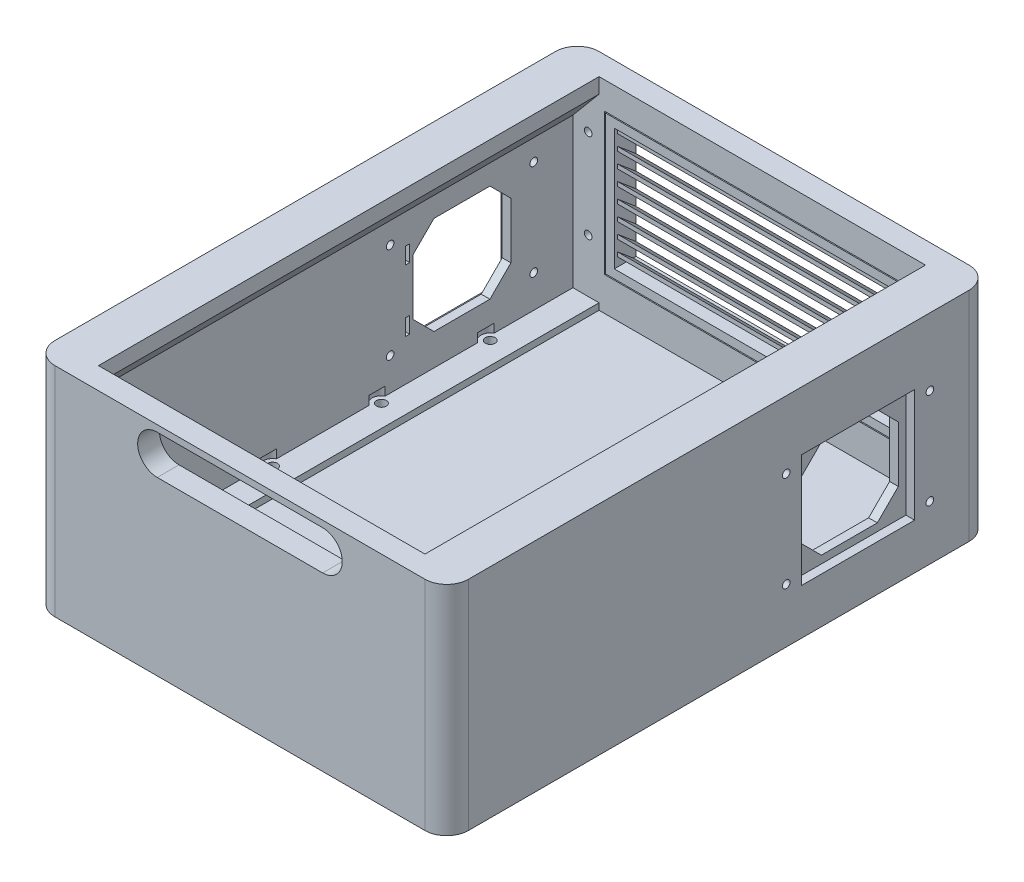
from build123d import *

# Parameters (mm, degrees)
CROQUIS1_W              = 190
CROQUIS1_H              = 250
SALIENTE_EXTRUIR1_DEPTH = 100
VACIADO1_T              = -10
CORTAR_EXTRUIR1_REACH   = 252
REDONDEO1_R             = 10
CROQUIS5_W              = 230
CROQUIS5_H              = 90
SALIENTE_EXTRUIR3_DEPTH = 10
CROQUIS6_W              = 230
CROQUIS6_H              = 90
SALIENTE_EXTRUIR4_DEPTH = 10
CROQUIS7_R              = 2.25
CORTAR_EXTRUIR3_DEPTH   = 10
CROQUIS10_W             = 20
CROQUIS10_H             = 15
CORTAR_EXTRUIR6_DEPTH   = 11
CROQUIS11_W             = 40
CROQUIS11_H             = 60
CORTAR_EXTRUIR7_DEPTH   = 7
CROQUIS13_W             = 145
CROQUIS13_H             = 65
CORTAR_EXTRUIR8_DEPTH   = 10
CROQUIS14_W             = 151
CROQUIS14_H             = 71
CORTAR_EXTRUIR9_DEPTH   = 5
CROQUIS15_W             = 150
CROQUIS15_H             = 70
SALIENTE_EXTRUIR5_DEPTH = 5
CROQUIS16_W             = 144
CROQUIS16_H             = 64
SALIENTE_EXTRUIR6_DEPTH = 5
CROQUIS17_W             = 136
CROQUIS17_H             = 56
CORTAR_EXTRUIR10_DEPTH  = 10
SALIENTE_EXTRUIR7_DEPTH = 136
CROQUIS19_W             = 9
CROQUIS19_H             = 9
CORTAR_EXTRUIR11_DEPTH  = 3.25
CROQUIS20_W             = 9
CROQUIS20_H             = 8
SALIENTE_EXTRUIR8_DEPTH = 3
CROQUIS21_R             = 1.75
CORTAR_EXTRUIR12_DEPTH  = 15
CROQUIS22_R             = 2
CORTAR_EXTRUIR13_DEPTH  = 0.5
CORTAR_EXTRUIR14_DEPTH  = 230
CROQUIS26_R             = 4.25
CORTAR_EXTRUIR15_DEPTH  = 4
CROQUIS25_W             = 52
CROQUIS25_H             = 52
CORTAR_EXTRUIR16_DEPTH  = 4
CORTAR_EXTRUIR17_DEPTH  = 4
CROQUIS29_R             = 1.75
CORTAR_EXTRUIR18_DEPTH  = 8
CROQUIS30_W             = 2
CROQUIS30_H             = 7.5
CORTAR_EXTRUIR19_DEPTH  = 10


with BuildPart() as part:
    # Croquis1 → Saliente-Extruir1 (new body)
    with BuildSketch(Plane(origin=(0, 0, 0), x_dir=(1, 0, 0), z_dir=(0, 1, 0))):
        with Locations((95, 125)):
            Rectangle(CROQUIS1_W, CROQUIS1_H)
    extrude(amount=SALIENTE_EXTRUIR1_DEPTH)

    # Vaciado1
    vaciado1_openings = [part.faces().sort_by_distance(p)[0] for p in [
        (95, 100, -125),
    ]]
    offset(amount=VACIADO1_T, openings=vaciado1_openings, kind=Kind.INTERSECTION)

    # Croquis2 → Cortar-Extruir1 (cut, up to next)
    with BuildSketch(Plane.XY, mode=Mode.PRIVATE) as cortar_extruir1_sk1:
        with BuildLine():
            Line((57, 97), (133, 97))
            ThreePointArc((133, 97), (142, 88), (133, 79))
            Line((133, 79), (57, 79))
            ThreePointArc((57, 79), (48, 88), (57, 97))
        make_face()
    cortar_extruir1_tool1 = extrude(cortar_extruir1_sk1.sketch, amount=-CORTAR_EXTRUIR1_REACH, mode=Mode.PRIVATE) & part.part
    add(cortar_extruir1_tool1.solids().sort_by_distance((95, 88, 0))[0], mode=Mode.SUBTRACT)

    # Redondeo1
    redondeo1_edges = [part.edges().sort_by_distance(p)[0] for p in [
        (0, 50, -250),
        (190, 50, -250),
        (190, 50, 0),
        (0, 50, 0),
    ]]
    fillet(redondeo1_edges, radius=REDONDEO1_R)

    # Croquis5 → Saliente-Extruir3 (add)
    with BuildSketch(Plane(origin=(10, 0, 0), x_dir=(0, 0, -1), z_dir=(1, 0, 0))):
        with Locations((125, 55)):
            Rectangle(CROQUIS5_W, CROQUIS5_H)
    extrude(amount=SALIENTE_EXTRUIR3_DEPTH)

    # Croquis6 → Saliente-Extruir4 (add)
    with BuildSketch(Plane.ZY.offset(-180)):
        with Locations((-125, 55)):
            Rectangle(CROQUIS6_W, CROQUIS6_H)
    extrude(amount=SALIENTE_EXTRUIR4_DEPTH)

    # Croquis7 → Cortar-Extruir3 (cut)
    with BuildSketch(Plane.XZ):
        with Locations((10, -50)):
            Circle(CROQUIS7_R)
        with Locations((10, -100)):
            Circle(CROQUIS7_R)
        with Locations((10, -150)):
            Circle(CROQUIS7_R)
        with Locations((10, -200)):
            Circle(CROQUIS7_R)
        with Locations((180, -200)):
            Circle(CROQUIS7_R)
        with Locations((180, -150)):
            Circle(CROQUIS7_R)
        with Locations((180, -100)):
            Circle(CROQUIS7_R)
        with Locations((180, -50)):
            Circle(CROQUIS7_R)
    extrude(amount=-CORTAR_EXTRUIR3_DEPTH, mode=Mode.SUBTRACT)

    # Croquis10 → Cortar-Extruir6 (cut, through all)
    with BuildSketch(Plane(origin=(0, 10, 0), x_dir=(1, 0, 0), z_dir=(0, 1, 0))):
        with Locations((95, 212)):
            Rectangle(CROQUIS10_W, CROQUIS10_H)
    extrude(amount=-CORTAR_EXTRUIR6_DEPTH, mode=Mode.SUBTRACT)

    # Croquis11 → Cortar-Extruir7 (cut)
    with BuildSketch(Plane(origin=(0, 10, 0), x_dir=(1, 0, 0), z_dir=(0, 1, 0))):
        with Locations((95, 40)):
            Rectangle(CROQUIS11_W, CROQUIS11_H)
    extrude(amount=-CORTAR_EXTRUIR7_DEPTH, mode=Mode.SUBTRACT)

    # Croquis13 → Cortar-Extruir8 (cut)
    with BuildSketch(Plane(origin=(0, 0, -250), x_dir=(-1, 0, 0), z_dir=(0, 0, -1))):
        with Locations((-95, 55)):
            Rectangle(CROQUIS13_W, CROQUIS13_H)
    extrude(amount=-CORTAR_EXTRUIR8_DEPTH, mode=Mode.SUBTRACT)

    # Croquis14 → Cortar-Extruir9 (cut)
    with BuildSketch(Plane(origin=(0, 0, -250), x_dir=(-1, 0, 0), z_dir=(0, 0, -1))):
        with Locations((-95, 55)):
            Rectangle(CROQUIS14_W, CROQUIS14_H)
    extrude(amount=-CORTAR_EXTRUIR9_DEPTH, mode=Mode.SUBTRACT)

    # Croquis19 → Cortar-Extruir11 (cut)
    with BuildSketch(Plane(origin=(0, 0, -250), x_dir=(-1, 0, 0), z_dir=(0, 0, -1))):
        with Locations((-175, 75.5)):
            Rectangle(CROQUIS19_W, CROQUIS19_H)
        with Locations((-175, 34.5)):
            Rectangle(CROQUIS19_W, CROQUIS19_H)
        with Locations((-15, 75.5)):
            Rectangle(CROQUIS19_W, CROQUIS19_H)
        with Locations((-15, 34.5)):
            Rectangle(CROQUIS19_W, CROQUIS19_H)
    extrude(amount=-CORTAR_EXTRUIR11_DEPTH, mode=Mode.SUBTRACT)


with BuildPart() as body_2:
    # Croquis15 → Saliente-Extruir5 (new body)
    with BuildSketch(Plane(origin=(0, 0, -245), x_dir=(-1, 0, 0), z_dir=(0, 0, -1))):
        with Locations((-95, 55)):
            Rectangle(CROQUIS15_W, CROQUIS15_H)
    extrude(amount=SALIENTE_EXTRUIR5_DEPTH)

    # Croquis16 → Saliente-Extruir6 (add)
    with BuildSketch(Plane.XY.offset(-245)):
        with Locations((95, 55)):
            Rectangle(CROQUIS16_W, CROQUIS16_H)
    extrude(amount=SALIENTE_EXTRUIR6_DEPTH)

    # Croquis17 → Cortar-Extruir10 (cut)
    with BuildSketch(Plane(origin=(0, 0, -250), x_dir=(-1, 0, 0), z_dir=(0, 0, -1))):
        with Locations((-95, 55)):
            Rectangle(CROQUIS17_W, CROQUIS17_H)
    extrude(amount=-CORTAR_EXTRUIR10_DEPTH, mode=Mode.SUBTRACT)

    # Croquis18 → Saliente-Extruir7 (add)
    with BuildSketch(Plane.ZY.offset(-163)):
        Polygon((-250, 74.867653135), (-241.5, 82), (-241.5, 80.041889066), (-250, 72.909542201), align=None)
        Polygon((-250, 65.909542201), (-250, 67.867653135), (-241.5, 75), (-241.5, 73.041889066), align=None)
        Polygon((-250, 58.909542201), (-250, 60.867653135), (-241.5, 68), (-241.5, 66.041889066), align=None)
        Polygon((-250, 51.909542201), (-250, 53.867653135), (-241.5, 61), (-241.5, 59.041889066), align=None)
        Polygon((-250, 44.909542201), (-250, 46.867653135), (-241.5, 54), (-241.5, 52.041889066), align=None)
        Polygon((-250, 37.909542201), (-250, 39.867653135), (-241.5, 47), (-241.5, 45.041889066), align=None)
        Polygon((-250, 30.909542201), (-250, 32.867653135), (-241.5, 40), (-241.5, 38.041889066), align=None)
        Polygon((-250, 23.909542201), (-250, 25.867653135), (-241.5, 33), (-241.5, 31.041889066), align=None)
    extrude(amount=SALIENTE_EXTRUIR7_DEPTH)

    # Croquis20 → Saliente-Extruir8 (add)
    with BuildSketch(Plane(origin=(0, 0, -250), x_dir=(-1, 0, 0), z_dir=(0, 0, -1))):
        with Locations((-174.5, 75.5)):
            Rectangle(CROQUIS20_W, CROQUIS20_H)
        with Locations((-174.5, 34.5)):
            Rectangle(CROQUIS20_W, CROQUIS20_H)
        with Locations((-15.5, 75.5)):
            Rectangle(CROQUIS20_W, CROQUIS20_H)
        with Locations((-15.5, 34.5)):
            Rectangle(CROQUIS20_W, CROQUIS20_H)
    extrude(amount=-SALIENTE_EXTRUIR8_DEPTH)


with BuildPart() as cortar_extruir12_tool:
    # Croquis21 → Cortar-Extruir12 (new body)
    with BuildSketch(Plane(origin=(0, 0, -250), x_dir=(-1, 0, 0), z_dir=(0, 0, -1))):
        with Locations((-175, 75.5)):
            Circle(CROQUIS21_R)
        with Locations((-175, 34.5)):
            Circle(CROQUIS21_R)
        with Locations((-15, 75.5)):
            Circle(CROQUIS21_R)
        with Locations((-15, 34.5)):
            Circle(CROQUIS21_R)
    extrude(amount=-CORTAR_EXTRUIR12_DEPTH)


with BuildPart() as part_1:
    add(part.part)

    # Cortar-Extruir12: cut by cortar_extruir12_tool
    add(cortar_extruir12_tool.part, mode=Mode.SUBTRACT)

    # Croquis24 → Cortar-Extruir14 (cut)
    with BuildSketch(Plane.XY.offset(-240)):
        Polygon((20, 93), (8, 78.698956889), (8, 10), (20, 10), (20, 7), (170, 7), (170, 10), (182, 10), (182, 78.698956889), (170, 93), align=None)
    extrude(amount=CORTAR_EXTRUIR14_DEPTH, mode=Mode.SUBTRACT)

    # Croquis26 → Cortar-Extruir15 (cut)
    with BuildSketch(Plane(origin=(0, 10, 0), x_dir=(1, 0, 0), z_dir=(0, 1, 0))):
        with Locations((10, 200)):
            Circle(CROQUIS26_R)
        with Locations((10, 150)):
            Circle(CROQUIS26_R)
        with Locations((10, 100)):
            Circle(CROQUIS26_R)
        with Locations((10, 50)):
            Circle(CROQUIS26_R)
        with Locations((180, 50)):
            Circle(CROQUIS26_R)
        with Locations((180, 100)):
            Circle(CROQUIS26_R)
        with Locations((180, 150)):
            Circle(CROQUIS26_R)
        with Locations((180, 200)):
            Circle(CROQUIS26_R)
    extrude(amount=CORTAR_EXTRUIR15_DEPTH, mode=Mode.SUBTRACT)

    # Croquis25 → Cortar-Extruir16 (cut)
    with BuildSketch(Plane.ZY):
        with Locations((-189, 47)):
            Rectangle(CROQUIS25_W, CROQUIS25_H)
    cortar_extruir16 = extrude(amount=-CORTAR_EXTRUIR16_DEPTH, mode=Mode.SUBTRACT)

    # Croquis28 → Cortar-Extruir17 (cut)
    with BuildSketch(Plane.ZY.offset(-4)):
        Polygon((-211.5, 34.144660941), (-211.5, 59.855339059), (-201.855339059, 69.5), (-176.144660941, 69.5), (-166.5, 59.855339059), (-166.5, 34.144660941), (-176.144660941, 24.5), (-201.855339059, 24.5), align=None)
    cortar_extruir17 = extrude(amount=-CORTAR_EXTRUIR17_DEPTH, mode=Mode.SUBTRACT)

    # Croquis29 → Cortar-Extruir18 (cut)
    with BuildSketch(Plane.ZY):
        with Locations((-222, 69)):
            Circle(CROQUIS29_R)
        with Locations((-156, 69)):
            Circle(CROQUIS29_R)
        with Locations((-156, 25)):
            Circle(CROQUIS29_R)
        with Locations((-222, 25)):
            Circle(CROQUIS29_R)
    cortar_extruir18 = extrude(amount=-CORTAR_EXTRUIR18_DEPTH, mode=Mode.SUBTRACT)

    # Simetría1: Cortar-Extruir16, Cortar-Extruir17, Cortar-Extruir18 across plane
    add(cortar_extruir16.mirror(Plane.ZY.offset(-95)), mode=Mode.SUBTRACT)
    add(cortar_extruir17.mirror(Plane.ZY.offset(-95)), mode=Mode.SUBTRACT)
    add(cortar_extruir18.mirror(Plane.ZY.offset(-95)), mode=Mode.SUBTRACT)

    # Croquis30 → Cortar-Extruir19 (cut)
    with BuildSketch(Plane.ZY.offset(-4)):
        with Locations((-164, 61.25)):
            Rectangle(CROQUIS30_W, CROQUIS30_H)
        with Locations((-164, 32.75)):
            Rectangle(CROQUIS30_W, CROQUIS30_H)
    cortar_extruir19 = extrude(amount=-CORTAR_EXTRUIR19_DEPTH, mode=Mode.SUBTRACT)

    # Simetría2: Cortar-Extruir19 across plane
    add(cortar_extruir19.mirror(Plane.ZY.offset(-95)), mode=Mode.SUBTRACT)


with BuildPart() as body_2_1:
    add(body_2.part)

    # Cortar-Extruir12: cut by cortar_extruir12_tool
    add(cortar_extruir12_tool.part, mode=Mode.SUBTRACT)

    # Croquis22 → Cortar-Extruir13 (cut)
    with BuildSketch(Plane(origin=(0, 0, -250), x_dir=(-1, 0, 0), z_dir=(0, 0, -1))):
        with Locations((-175, 75.5)):
            Circle(CROQUIS22_R)
        with Locations((-175, 34.5)):
            Circle(CROQUIS22_R)
        with Locations((-15, 34.5)):
            Circle(CROQUIS22_R)
        with Locations((-15, 75.5)):
            Circle(CROQUIS22_R)
    extrude(amount=-CORTAR_EXTRUIR13_DEPTH, mode=Mode.SUBTRACT)


solid = Compound([part_1.part, body_2_1.part])
